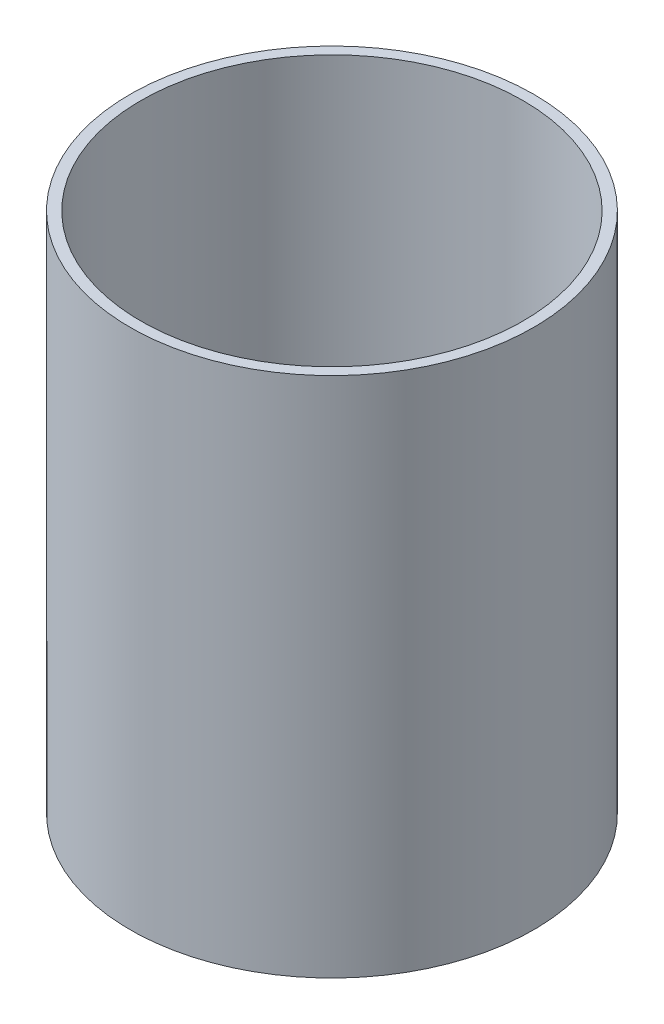
from build123d import *

# Parameters (mm, degrees)
SKETCH1_W = 1.524
SKETCH1_H = 73.66


with BuildPart() as part:
    # Sketch1 → Revolve1 (revolve)
    with BuildSketch(Plane.XY):
        with Locations((27.7368, 36.83)):
            Rectangle(SKETCH1_W, SKETCH1_H)
    revolve(axis=Axis((0, -13.97, 0), (0, 1, 0)))


solid = part.part
